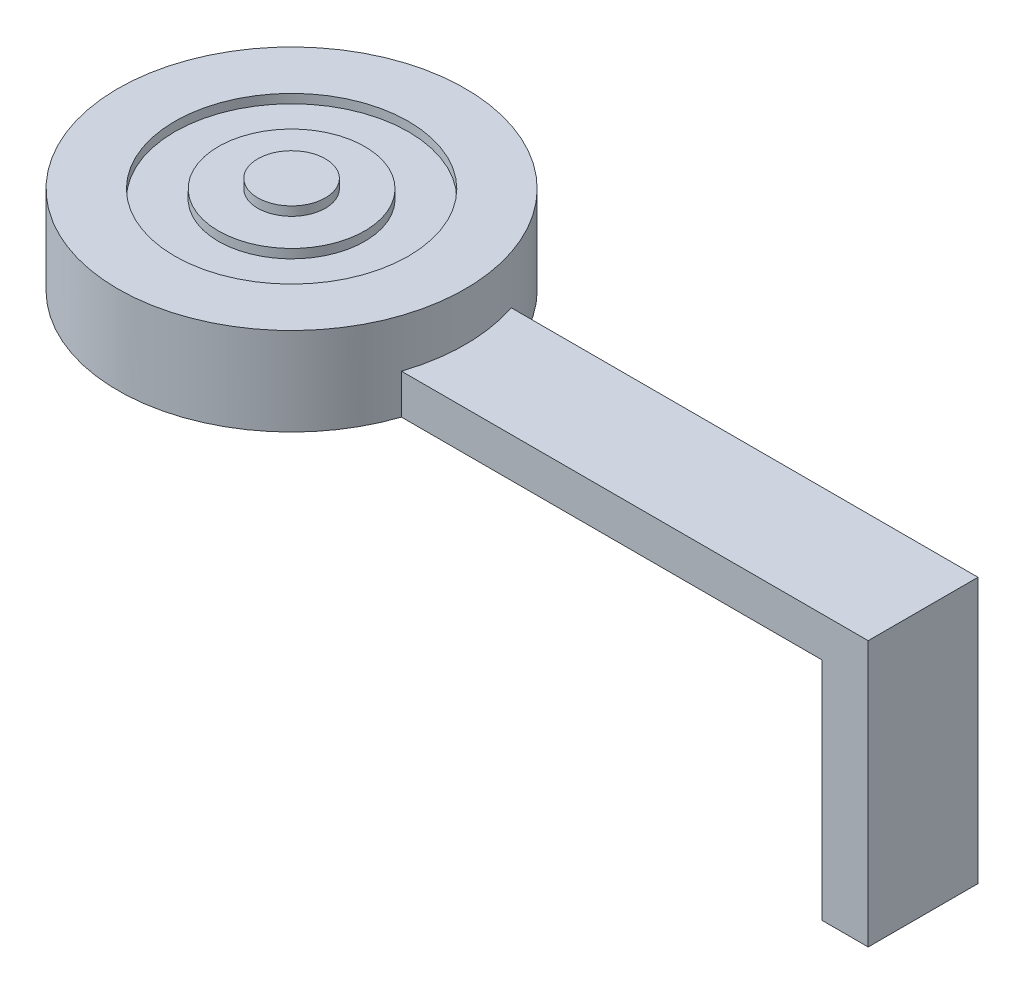
from build123d import *

# Parameters (mm, degrees)
SKETCH1_R           = 9.779
BOSS_EXTRUDE1_DEPTH = 4.953
SKETCH2_R           = 1.905
BOSS_EXTRUDE2_DEPTH = 0.508
SKETCH3_R           = 6.578574276
SKETCH3_R_2         = 4.119665811
CUT_EXTRUDE1_DEPTH  = 0.508
SKETCH4_W           = 6.183927722
SKETCH4_H           = 2.240204311
BOSS_EXTRUDE3_DEPTH = 35.56
SKETCH5_W           = 2.60391419
SKETCH5_H           = 6.183927722
BOSS_EXTRUDE4_DEPTH = 12.7


with BuildPart() as part:
    # Sketch1 → Boss-Extrude1 (new body)
    with BuildSketch(Plane(origin=(0, 0, 0), x_dir=(1, 0, 0), z_dir=(0, 1, 0))):
        Circle(SKETCH1_R)
    extrude(amount=BOSS_EXTRUDE1_DEPTH)

    # Sketch2 → Boss-Extrude2 (add)
    with BuildSketch(Plane(origin=(0, 4.953, 0), x_dir=(1, 0, 0), z_dir=(0, 1, 0))):
        Circle(SKETCH2_R)
    extrude(amount=BOSS_EXTRUDE2_DEPTH)

    # Sketch3 → Cut-Extrude1 (cut)
    with BuildSketch(Plane(origin=(0, 4.953, 0), x_dir=(1, 0, 0), z_dir=(0, 1, 0))):
        Circle(SKETCH3_R)
        Circle(SKETCH3_R_2, mode=Mode.SUBTRACT)
    extrude(amount=-CUT_EXTRUDE1_DEPTH, mode=Mode.SUBTRACT)

    # Sketch4 → Boss-Extrude3 (add)
    with BuildSketch(Plane(origin=(0, 0, 0), x_dir=(0, 0, -1), z_dir=(1, 0, 0))):
        with Locations((0, 1.120102156)):
            Rectangle(SKETCH4_W, SKETCH4_H)
    extrude(amount=BOSS_EXTRUDE3_DEPTH)

    # Sketch5 → Boss-Extrude4 (add)
    with BuildSketch(Plane.XZ):
        with Locations((34.258042905, 0)):
            Rectangle(SKETCH5_W, SKETCH5_H)
    extrude(amount=BOSS_EXTRUDE4_DEPTH)


solid = part.part
